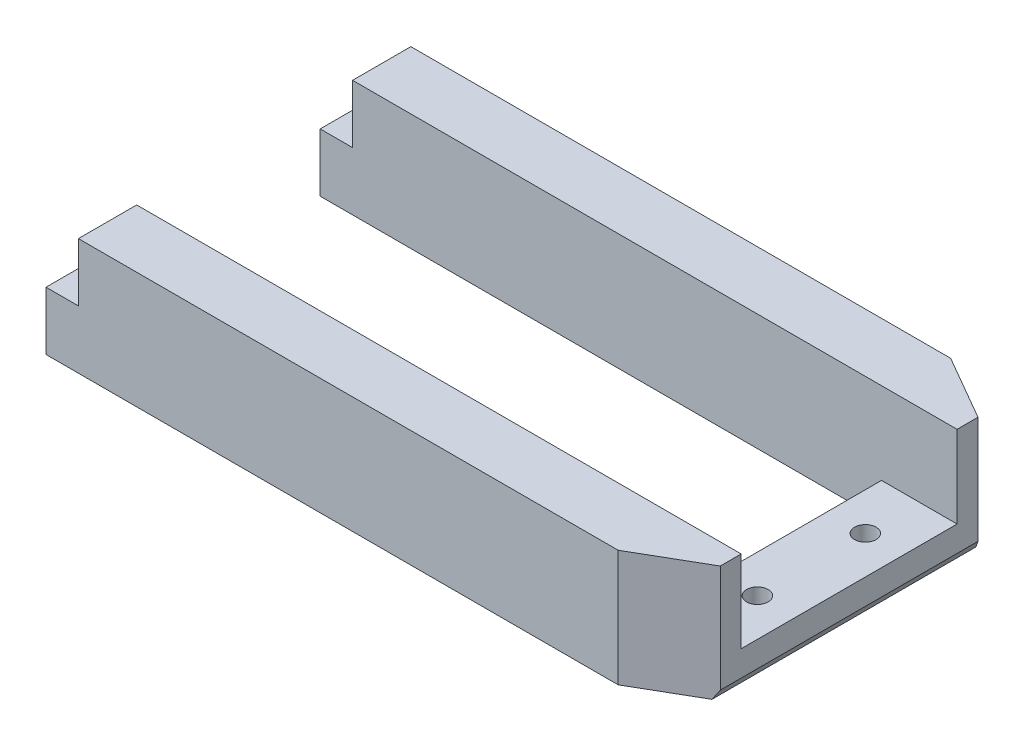
from build123d import *

# Parameters (mm, degrees)
SALIENTE_EXTRUIR1_DEPTH = 13
CROQUIS2_W              = 7
CROQUIS2_H              = 20
CORTAR_EXTRUIR1_DEPTH   = 7.6
CROQUIS3_W              = 3
CROQUIS3_H              = 5.399999618
CROQUIS3_H_2            = 5.399999619
CORTAR_EXTRUIR2_DEPTH   = 5.4
CROQUIS4_R              = 1
CORTAR_EXTRUIR3_DEPTH   = 10.4
CORTAR_EXTRUIR4_DEPTH   = 32.4
CROQUIS6_W              = 66.642206308
CROQUIS6_H              = 2.2
CORTAR_EXTRUIR5_DEPTH   = 35


with BuildPart() as part:
    # Croquis1 → Saliente-Extruir1 (new body)
    with BuildSketch(Plane(origin=(0, 0, 0), x_dir=(1, 0, 0), z_dir=(0, 1, 0))):
        Polygon((-29.00453802, -14.532941153), (-29.00453802, -9.132941534), (22.99546198, -9.132941534), (22.99546198, 10.867058466), (-29.00453802, 10.867058466), (-29.00453802, 16.267058084), (23.998794118, 16.267058084), (29.99546198, 12.804880808), (29.99546198, -11.070763876), (23.998794118, -14.532941153), align=None)
    extrude(amount=SALIENTE_EXTRUIR1_DEPTH)

    # Croquis2 → Cortar-Extruir1 (cut)
    with BuildSketch(Plane(origin=(0, 13, 0), x_dir=(1, 0, 0), z_dir=(0, 1, 0))):
        with Locations((26.49546198, 0.867058466)):
            Rectangle(CROQUIS2_W, CROQUIS2_H)
    extrude(amount=-CORTAR_EXTRUIR1_DEPTH, mode=Mode.SUBTRACT)

    # Croquis3 → Cortar-Extruir2 (cut)
    with BuildSketch(Plane(origin=(0, 13, 0), x_dir=(1, 0, 0), z_dir=(0, 1, 0))):
        with Locations((-27.50453802, 13.567058275)):
            Rectangle(CROQUIS3_W, CROQUIS3_H)
        with Locations((-27.50453802, -11.832941343)):
            Rectangle(CROQUIS3_W, CROQUIS3_H_2)
    extrude(amount=-CORTAR_EXTRUIR2_DEPTH, mode=Mode.SUBTRACT)

    # Croquis4 → Cortar-Extruir3 (cut)
    with BuildSketch(Plane(origin=(0, 5.4, 0), x_dir=(1, 0, 0), z_dir=(0, 1, 0))):
        with Locations((26.49546198, 5.867058466)):
            Circle(CROQUIS4_R)
        with Locations((26.49546198, -4.132941534)):
            Circle(CROQUIS4_R)
    extrude(amount=-CORTAR_EXTRUIR3_DEPTH, mode=Mode.SUBTRACT)

    # Croquis5 → Cortar-Extruir4 (cut)
    with BuildSketch(Plane.XY.offset(14.532941153)):
        Polygon((28.23546198, 0), (29.99546198, 3.04), (29.99546198, 0), align=None)
    extrude(amount=-CORTAR_EXTRUIR4_DEPTH, mode=Mode.SUBTRACT)

    # Croquis6 → Cortar-Extruir5 (cut)
    with BuildSketch(Plane(origin=(0, 0, -16.267058084), x_dir=(-1, 0, 0), z_dir=(0, 0, -1))):
        with Locations((-4.316565134, 1.1)):
            Rectangle(CROQUIS6_W, CROQUIS6_H)
    extrude(amount=-CORTAR_EXTRUIR5_DEPTH, mode=Mode.SUBTRACT)


solid = part.part
